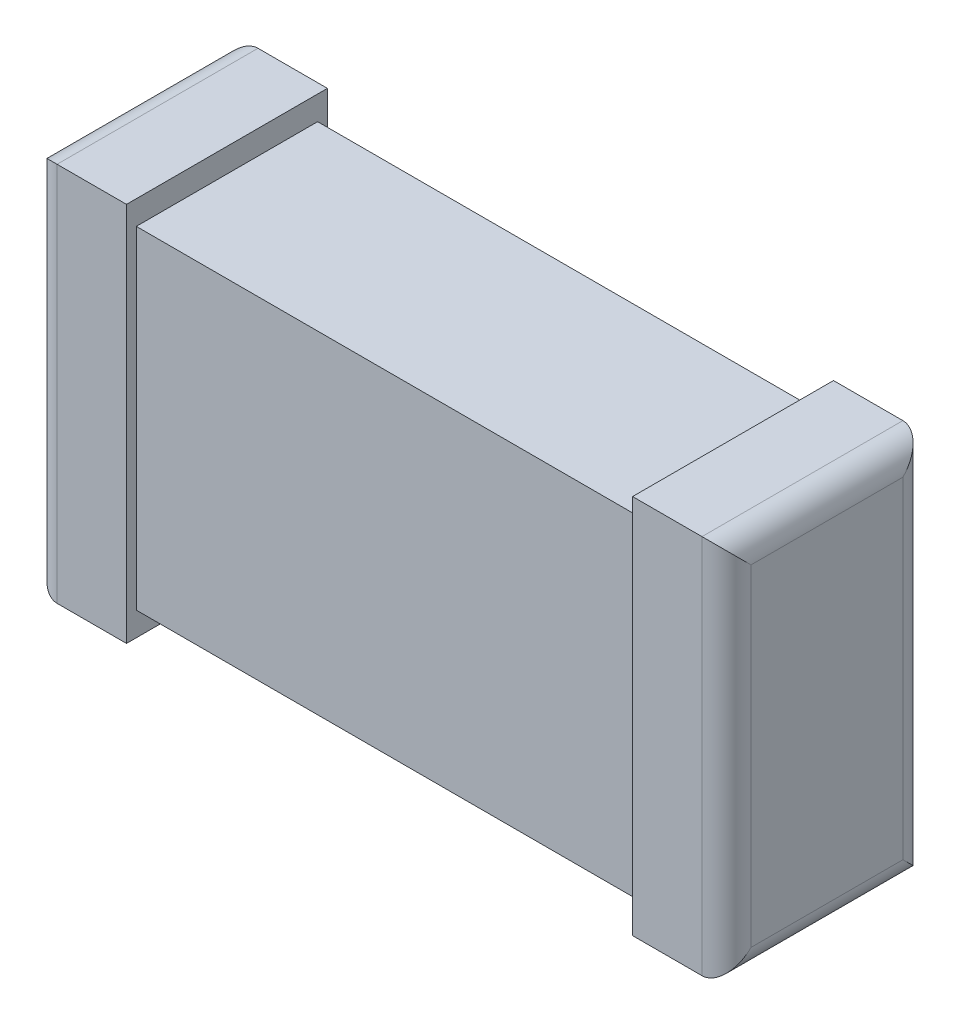
from build123d import *

# Parameters (mm, degrees)
ESQUISSE1_W             = 7.08
ESQUISSE1_H             = 3.88
BOSS_EXTRU_1_DEPTH      = 2.05
ESQUISSE3_W             = 5.163612044
ESQUISSE3_H             = 0.48908098
ENL_V_MAT_EXTRU_1_DEPTH = 2.05
ESQUISSE4_W             = 5.163612044
ESQUISSE4_H             = 3.39091902
ENL_V_MAT_EXTRU_2_DEPTH = 0.1
ESQUISSE5_W             = 5.163612044
ESQUISSE5_H             = 3.39091902
ENL_V_MAT_EXTRU_3_DEPTH = 0.1
CONG_1_R                = 0.25


with BuildPart() as part:
    # Esquisse1 → Boss.-Extru.1 (new body)
    with BuildSketch(Plane.XY):
        Rectangle(ESQUISSE1_W, ESQUISSE1_H)
    extrude(amount=BOSS_EXTRU_1_DEPTH)

    # Esquisse3 → Enlèv. mat.-Extru.1 (cut)
    with BuildSketch(Plane.XY.offset(2.05)):
        with Locations((0, 1.94)):
            Rectangle(ESQUISSE3_W, ESQUISSE3_H)
        with Locations((0, -1.94)):
            Rectangle(ESQUISSE3_W, ESQUISSE3_H)
    extrude(amount=-ENL_V_MAT_EXTRU_1_DEPTH, mode=Mode.SUBTRACT)

    # Esquisse4 → Enlèv. mat.-Extru.2 (cut)
    with BuildSketch(Plane.XY.offset(2.05)):
        Rectangle(ESQUISSE4_W, ESQUISSE4_H)
    extrude(amount=-ENL_V_MAT_EXTRU_2_DEPTH, mode=Mode.SUBTRACT)

    # Esquisse5 → Enlèv. mat.-Extru.3 (cut)
    with BuildSketch(Plane(origin=(0, 0, 0), x_dir=(-1, 0, 0), z_dir=(0, 0, -1))):
        Rectangle(ESQUISSE5_W, ESQUISSE5_H)
    extrude(amount=-ENL_V_MAT_EXTRU_3_DEPTH, mode=Mode.SUBTRACT)

    # Congé1
    cong_1_edges = [part.edges().sort_by_distance(p)[0] for p in [
        (-3.54, 0, 2.05),
        (3.54, 0, 2.05),
        (-3.54, 0, 0),
        (3.54, 0, 0),
        (3.54, -1.94, 1.025),
        (-3.54, -1.94, 1.025),
        (-3.54, 1.94, 1.025),
        (3.54, 1.94, 1.025),
    ]]
    fillet(cong_1_edges, radius=CONG_1_R)


solid = part.part
